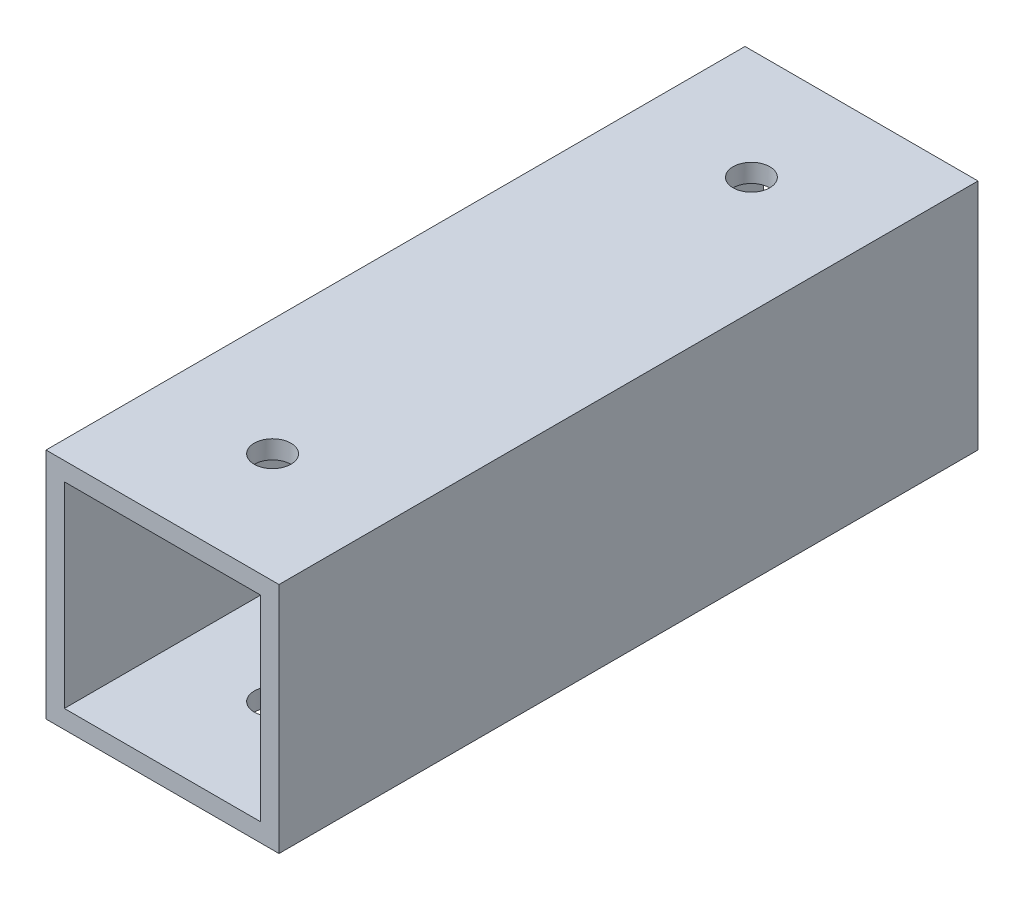
from build123d import *

# Parameters (mm, degrees)
SKETCH1_W           = 25.4
SKETCH1_H           = 25.4
SKETCH1_W_2         = 21.4
SKETCH1_H_2         = 21.4
BOSS_EXTRUDE1_DEPTH = 76.2
SKETCH3_R           = 2
CUT_EXTRUDE2_DEPTH  = 26.4


with BuildPart() as part:
    # Sketch1 → Boss-Extrude1 (new body)
    with BuildSketch(Plane.XY):
        with Locations((12.7, 12.7)):
            Rectangle(SKETCH1_W, SKETCH1_H)
        with Locations((12.7, 12.7)):
            Rectangle(SKETCH1_W_2, SKETCH1_H_2, mode=Mode.SUBTRACT)
    extrude(amount=BOSS_EXTRUDE1_DEPTH)

    # Sketch3 → Cut-Extrude2 (cut, through all)
    with BuildSketch(Plane(origin=(0, 25.4, 0), x_dir=(1, 0, 0), z_dir=(0, 1, 0))):
        with Locations((12.7, -12)):
            Circle(SKETCH3_R)
        with Locations((12.7, -64.2)):
            Circle(SKETCH3_R)
    extrude(amount=-CUT_EXTRUDE2_DEPTH, mode=Mode.SUBTRACT)


solid = part.part
